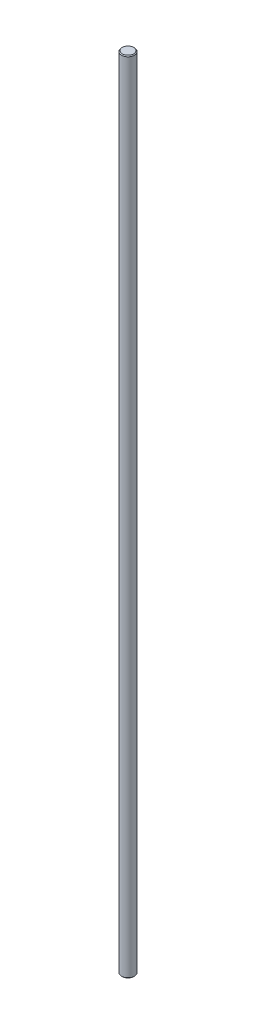
from build123d import *

# Parameters (mm, degrees)
SKETCH1_R           = 4
BOSS_EXTRUDE1_DEPTH = 495.3
CHAMFER1_SIZE       = 0.5


with BuildPart() as part:
    # Sketch1 → Boss-Extrude1 (new body)
    with BuildSketch(Plane(origin=(0, 0, 0), x_dir=(1, 0, 0), z_dir=(0, 1, 0))):
        Circle(SKETCH1_R)
    extrude(amount=BOSS_EXTRUDE1_DEPTH)

    # Chamfer1
    chamfer1_edges = [part.edges().sort_by_distance(p)[0] for p in [
        (-4, 0, 0),
        (-4, 495.3, 0),
    ]]
    chamfer(chamfer1_edges, length=CHAMFER1_SIZE)


solid = part.part
